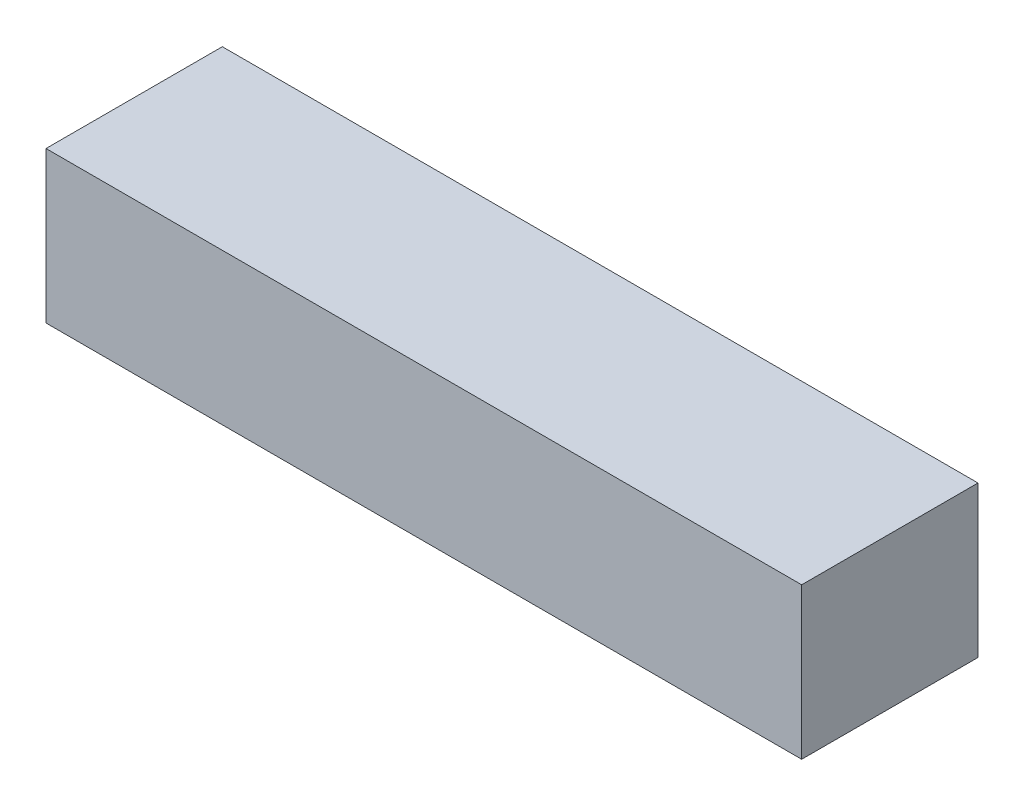
from build123d import *

# Parameters (mm, degrees)
SKETCH1_W           = 30
SKETCH1_H           = 7
BOSS_EXTRUDE1_DEPTH = 6


with BuildPart() as part:
    # Sketch1 → Boss-Extrude1 (new body)
    with BuildSketch(Plane(origin=(0, 0, 0), x_dir=(1, 0, 0), z_dir=(0, 1, 0))):
        with Locations((15, 3.5)):
            Rectangle(SKETCH1_W, SKETCH1_H)
    extrude(amount=BOSS_EXTRUDE1_DEPTH)


solid = part.part
